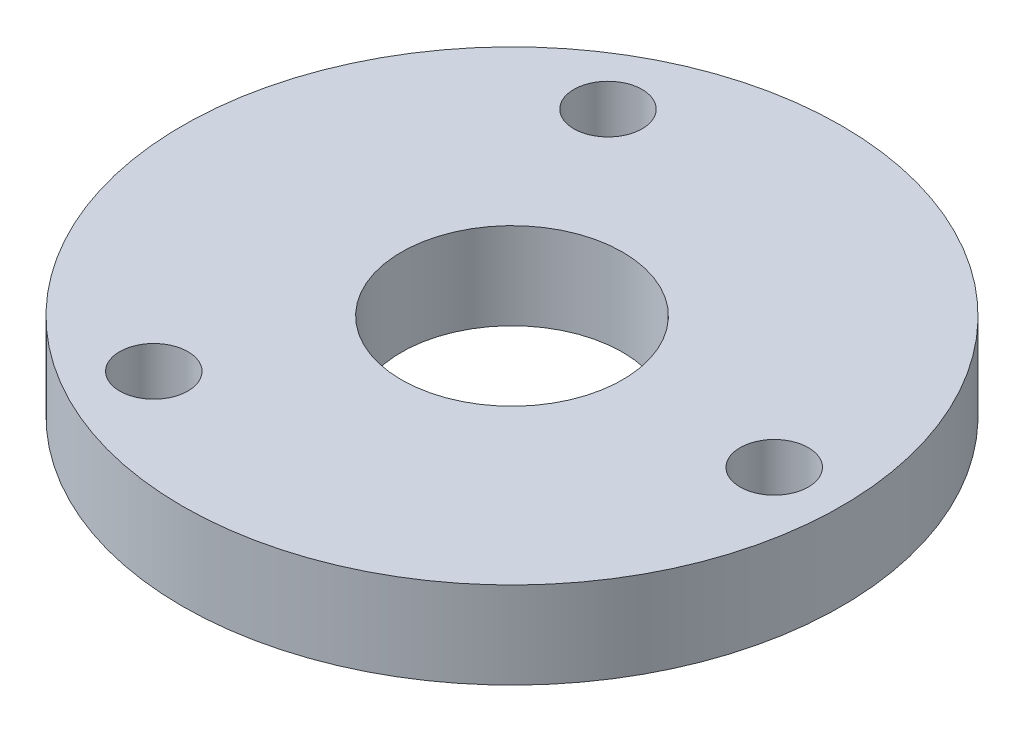
from build123d import *

# Parameters (mm, degrees)
SKETCH1_R           = 24.13
SKETCH1_R_2         = 2.5
SKETCH1_R_3         = 8.1
BOSS_EXTRUDE1_DEPTH = 6.35


with BuildPart() as part:
    # Sketch1 → Boss-Extrude1 (new body)
    with BuildSketch(Plane(origin=(0, 0, 0), x_dir=(1, 0, 0), z_dir=(0, 1, 0))):
        Circle(SKETCH1_R)
        with Locations((19.2, 0)):
            Circle(SKETCH1_R_2, mode=Mode.SUBTRACT)
        with Locations((-9.6, 16.627687753)):
            Circle(SKETCH1_R_2, mode=Mode.SUBTRACT)
        with Locations((-9.6, -16.627687753)):
            Circle(SKETCH1_R_2, mode=Mode.SUBTRACT)
        Circle(SKETCH1_R_3, mode=Mode.SUBTRACT)
    extrude(amount=BOSS_EXTRUDE1_DEPTH)


solid = part.part
